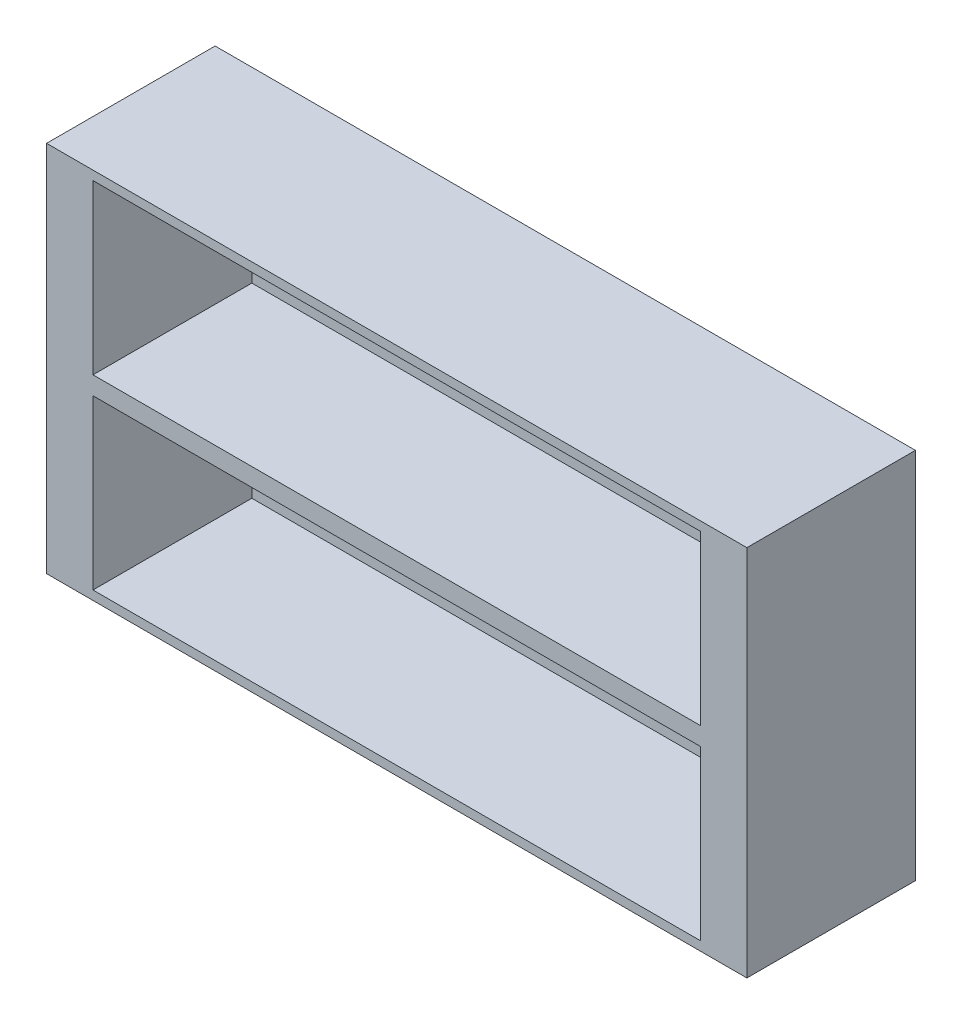
from build123d import *

# Parameters (mm, degrees)
SKETCH1_W           = 74.93
SKETCH1_H           = 39.878
BOSS_EXTRUDE1_DEPTH = 18.034
SKETCH2_R           = 1.5
CUT_EXTRUDE1_DEPTH  = 18.034
SKETCH3_W           = 65
SKETCH3_H           = 18
CUT_EXTRUDE2_DEPTH  = 17


with BuildPart() as part:
    # Sketch1 → Boss-Extrude1 (new body)
    with BuildSketch(Plane.XY):
        Rectangle(SKETCH1_W, SKETCH1_H)
    extrude(amount=BOSS_EXTRUDE1_DEPTH)

    # Sketch2 → Cut-Extrude1 (cut)
    with BuildSketch(Plane.XY.offset(18.034)):
        with Locations((0, -9.9695)):
            Circle(SKETCH2_R)
        with Locations((0, 9.9695)):
            Circle(SKETCH2_R)
    extrude(amount=-CUT_EXTRUDE1_DEPTH, mode=Mode.SUBTRACT)

    # Sketch3 → Cut-Extrude2 (cut)
    with BuildSketch(Plane.XY.offset(18.034)):
        with Locations((0, 9.9695)):
            Rectangle(SKETCH3_W, SKETCH3_H)
        with Locations((0, -9.9695)):
            Rectangle(SKETCH3_W, SKETCH3_H)
    extrude(amount=-CUT_EXTRUDE2_DEPTH, mode=Mode.SUBTRACT)


solid = part.part
